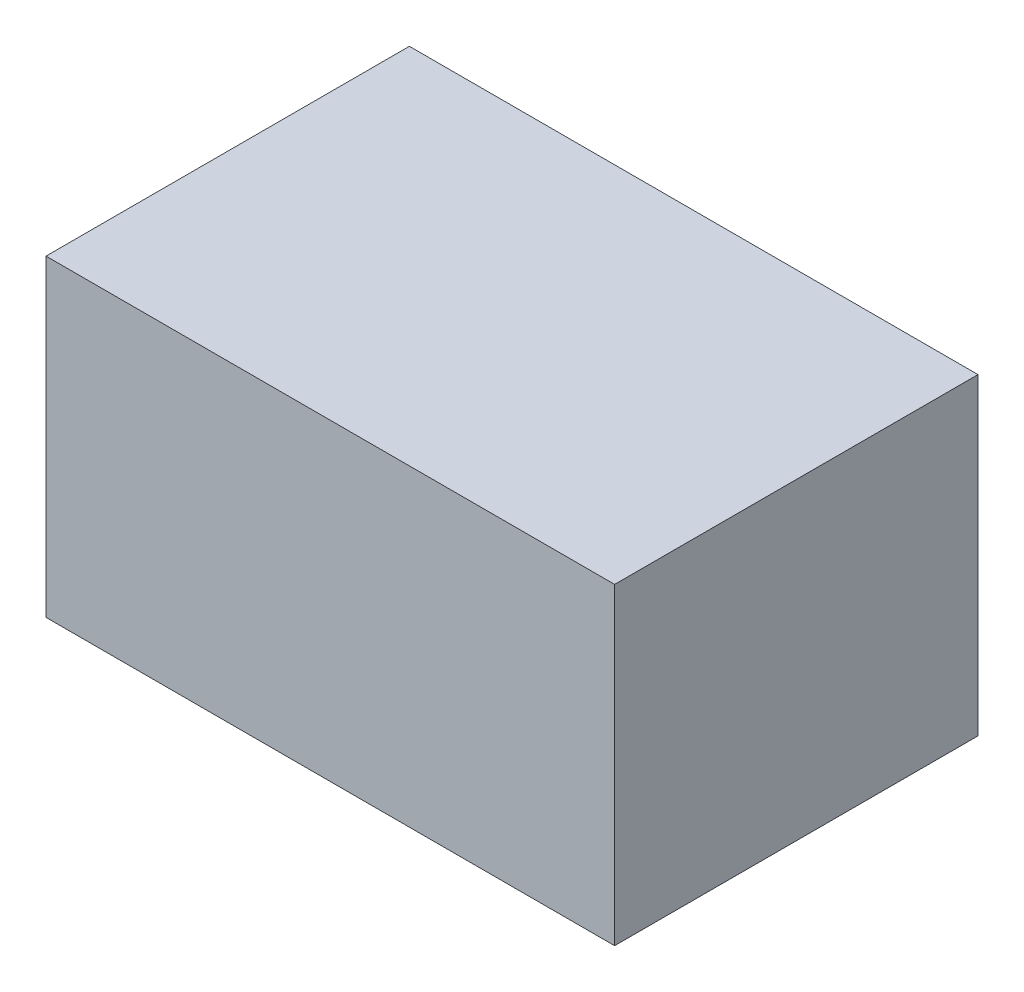
from build123d import *

# Parameters (mm, degrees)
SKETCH1_W           = 84.5
SKETCH1_H           = 54
BOSS_EXTRUDE2_DEPTH = 46.5


with BuildPart() as part:
    # Sketch1 → Boss-Extrude2 (new body)
    with BuildSketch(Plane(origin=(0, 0, 0), x_dir=(1, 0, 0), z_dir=(0, 1, 0))):
        with Locations((42.25, 27)):
            Rectangle(SKETCH1_W, SKETCH1_H)
    extrude(amount=BOSS_EXTRUDE2_DEPTH)


solid = part.part
